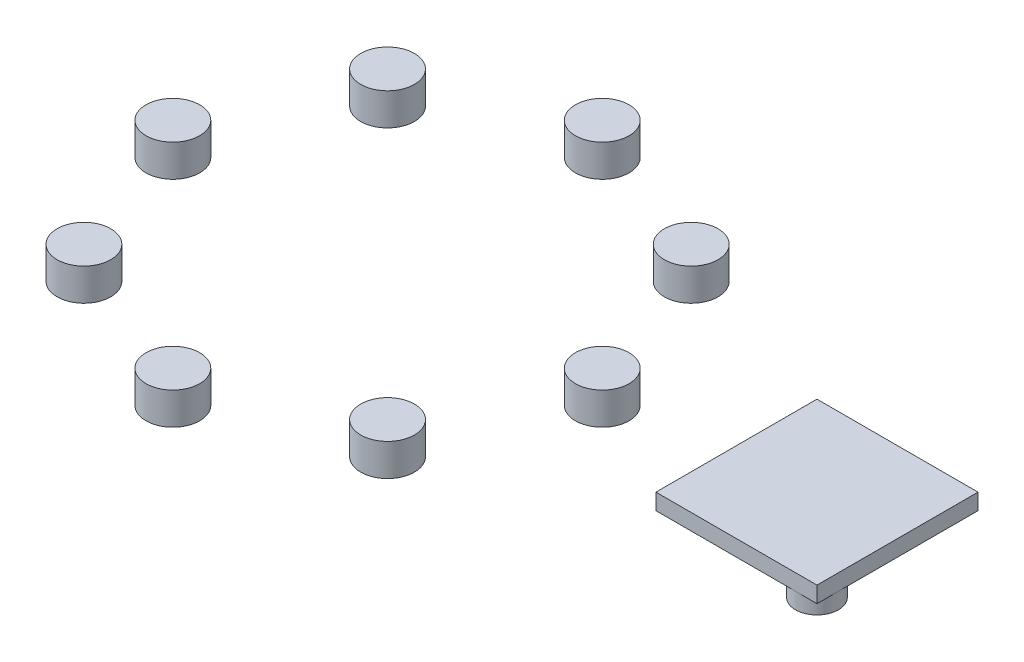
from build123d import *

# Parameters (mm, degrees)
SKETCH1_R             = 2.5
BOSS_EXTRUDE3_DEPTH   = 3
BOSS_EXTRUDE3_2_DEPTH = 3
BOSS_EXTRUDE3_3_DEPTH = 3
BOSS_EXTRUDE3_4_DEPTH = 3
BOSS_EXTRUDE3_5_DEPTH = 3
BOSS_EXTRUDE3_6_DEPTH = 3
BOSS_EXTRUDE3_7_DEPTH = 3
BOSS_EXTRUDE3_8_DEPTH = 3
SKETCH1_W             = 15
SKETCH1_H             = 15
BOSS_EXTRUDE3_9_DEPTH = 3
CUT_EXTRUDE1_DEPTH    = 1.5
CUT_EXTRUDE3_DEPTH    = 1.5


with BuildPart() as part:
    # Sketch1 → Boss-Extrude3 (new body)
    with BuildSketch(Plane(origin=(0, 0, 0), x_dir=(1, 0, 0), z_dir=(0, 1, 0))):
        with Locations((-35, 0)):
            Circle(SKETCH1_R)
    extrude(amount=BOSS_EXTRUDE3_DEPTH)


with BuildPart() as body_2:
    # Sketch1 → Boss-Extrude3 2 (new body)
    with BuildSketch(Plane(origin=(0, 0, 0), x_dir=(1, 0, 0), z_dir=(0, 1, 0))):
        with Locations((-29.142135624, 14.142135624)):
            Circle(SKETCH1_R)
    extrude(amount=BOSS_EXTRUDE3_2_DEPTH)


with BuildPart() as body_3:
    # Sketch1 → Boss-Extrude3 3 (new body)
    with BuildSketch(Plane(origin=(0, 0, 0), x_dir=(1, 0, 0), z_dir=(0, 1, 0))):
        with Locations((-15, 20)):
            Circle(SKETCH1_R)
    extrude(amount=BOSS_EXTRUDE3_3_DEPTH)


with BuildPart() as body_4:
    # Sketch1 → Boss-Extrude3 4 (new body)
    with BuildSketch(Plane(origin=(0, 0, 0), x_dir=(1, 0, 0), z_dir=(0, 1, 0))):
        with Locations((-0.857864376, 14.142135624)):
            Circle(SKETCH1_R)
    extrude(amount=BOSS_EXTRUDE3_4_DEPTH)


with BuildPart() as body_5:
    # Sketch1 → Boss-Extrude3 5 (new body)
    with BuildSketch(Plane(origin=(0, 0, 0), x_dir=(1, 0, 0), z_dir=(0, 1, 0))):
        with Locations((5, 0)):
            Circle(SKETCH1_R)
    extrude(amount=BOSS_EXTRUDE3_5_DEPTH)


with BuildPart() as body_6:
    # Sketch1 → Boss-Extrude3 6 (new body)
    with BuildSketch(Plane(origin=(0, 0, 0), x_dir=(1, 0, 0), z_dir=(0, 1, 0))):
        with Locations((-0.857864376, -14.142135624)):
            Circle(SKETCH1_R)
    extrude(amount=BOSS_EXTRUDE3_6_DEPTH)


with BuildPart() as body_7:
    # Sketch1 → Boss-Extrude3 7 (new body)
    with BuildSketch(Plane(origin=(0, 0, 0), x_dir=(1, 0, 0), z_dir=(0, 1, 0))):
        with Locations((-15, -20)):
            Circle(SKETCH1_R)
    extrude(amount=BOSS_EXTRUDE3_7_DEPTH)


with BuildPart() as body_8:
    # Sketch1 → Boss-Extrude3 8 (new body)
    with BuildSketch(Plane(origin=(0, 0, 0), x_dir=(1, 0, 0), z_dir=(0, 1, 0))):
        with Locations((-29.142135624, -14.142135624)):
            Circle(SKETCH1_R)
    extrude(amount=BOSS_EXTRUDE3_8_DEPTH)


with BuildPart() as body_9:
    # Sketch1 → Boss-Extrude3 9 (new body)
    with BuildSketch(Plane(origin=(0, 0, 0), x_dir=(1, 0, 0), z_dir=(0, 1, 0))):
        with Locations((25, 0)):
            Rectangle(SKETCH1_W, SKETCH1_H)
    extrude(amount=BOSS_EXTRUDE3_9_DEPTH)

    # Sketch2 → Cut-Extrude1 (cut)
    with BuildSketch(Plane.XZ):
        with BuildLine():
            Line((30.5, 7.5), (17.5, 7.5))
            Line((17.5, 7.5), (17.5, -5.5))
            ThreePointArc((17.5, -5.5), (20.914213562, -4.085786438), (19.5, -7.5))
            Line((19.5, -7.5), (32.5, -7.5))
            Line((32.5, -7.5), (32.5, 5.5))
            ThreePointArc((32.5, 5.5), (29.085786438, 4.085786438), (30.5, 7.5))
        make_face()
        with BuildLine():
            ThreePointArc((19.5, -7.5), (18.085786438, -6.914213562), (17.5, -5.5))
            Line((17.5, -5.5), (17.5, -7.5))
            Line((17.5, -7.5), (19.5, -7.5))
        make_face()
    extrude(amount=-CUT_EXTRUDE1_DEPTH, mode=Mode.SUBTRACT)

    # Sketch3 → Cut-Extrude3 (cut)
    with BuildSketch(Plane.XZ):
        with BuildLine():
            Line((32.5, 5.5), (32.5, 7.5))
            Line((32.5, 7.5), (30.5, 7.5))
            ThreePointArc((30.5, 7.5), (31.914213562, 6.914213562), (32.5, 5.5))
        make_face()
    extrude(amount=-CUT_EXTRUDE3_DEPTH, mode=Mode.SUBTRACT)


solid = Compound([part.part, body_2.part, body_3.part, body_4.part, body_5.part, body_6.part, body_7.part, body_8.part, body_9.part])
